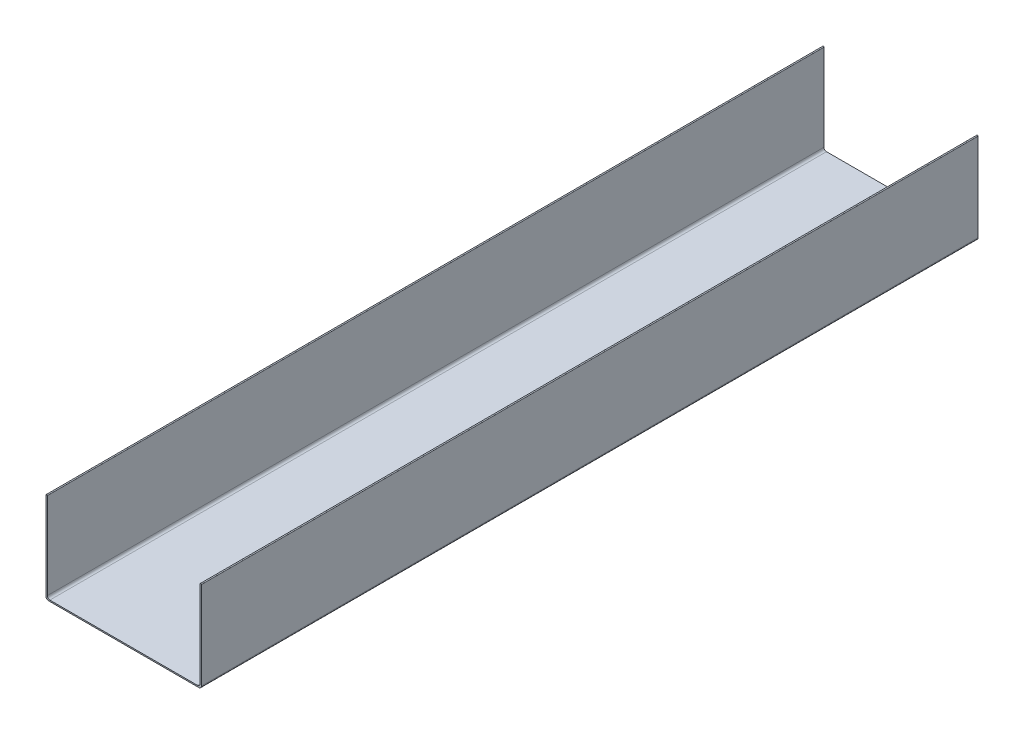
from build123d import *

# Parameters (mm, degrees)
BOSS_EXTRUDE1_DEPTH = 774.7


with BuildPart() as part:
    # Sketch1 → Boss-Extrude1 (new body)
    with BuildSketch(Plane.XY):
        with BuildLine():
            Line((0, 0), (0, -86.36))
            ThreePointArc((0, -86.36), (0.743948776, -88.156051224), (2.54, -88.9))
            Line((2.54, -88.9), (149.86, -88.9))
            ThreePointArc((149.86, -88.9), (151.656051224, -88.156051224), (152.4, -86.36))
            Line((152.4, -86.36), (152.4, 0))
            ThreePointArc((152.4, 0), (153.035, 0.635), (153.67, 0))
            Line((153.67, 0), (153.67, -87.63))
            ThreePointArc((153.67, -87.63), (152.926051224, -89.426051224), (151.13, -90.17))
            Line((151.13, -90.17), (1.27, -90.17))
            ThreePointArc((1.27, -90.17), (-0.526051224, -89.426051224), (-1.27, -87.63))
            Line((-1.27, -87.63), (-1.27, 0))
            ThreePointArc((-1.27, 0), (-0.635, 0.635), (0, 0))
        make_face()
    extrude(amount=BOSS_EXTRUDE1_DEPTH)


solid = part.part
